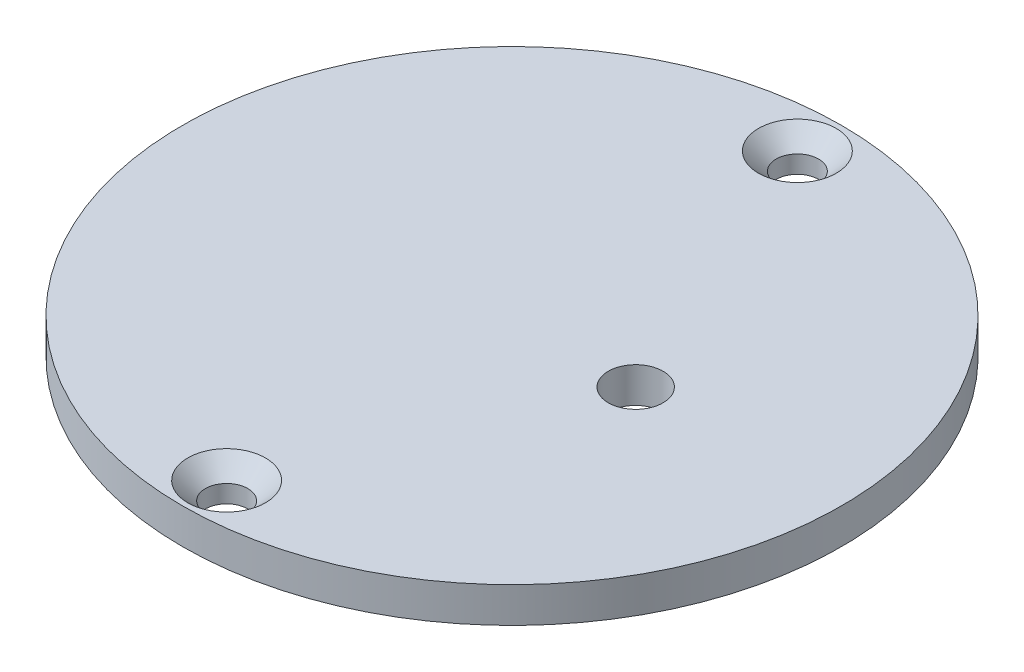
from build123d import *

# Parameters (mm, degrees)
SKETCH_1_R                 = 18.65
EXTRUDE_1_DEPTH            = 2
SKETCH_2_R                 = 1.55
CUT_EXTRUDE_1_DEPTH        = 2
HOLE_WIZARD_M21_AT_2_COUNT = 2
HOLE_WIZARD_M21_AT_2_PITCH = 32.3


with BuildPart() as part:
    # Эскиз1 → Бобышка-Вытянуть1 (new body)
    with BuildSketch(Plane(origin=(0, 0, 0), x_dir=(1, 0, 0), z_dir=(0, 1, 0))):
        Circle(SKETCH_1_R)
    extrude(amount=EXTRUDE_1_DEPTH)

    # Эскиз2 → Вырез-Вытянуть1 (cut)
    with BuildSketch(Plane(origin=(0, 2, 0), x_dir=(1, 0, 0), z_dir=(0, 1, 0))):
        with Locations((7, 0)):
            Circle(SKETCH_2_R)
    extrude(amount=-CUT_EXTRUDE_1_DEPTH, mode=Mode.SUBTRACT)

    # Эскиз4 → Зенковка для  винта с плоской головкой M21 (revolve, cut)
    with BuildSketch(Plane(origin=(0, 2, -16.15), x_dir=(0, 0, 1), z_dir=(1, 0, 0))):
        Polygon((0, 0), (0, 2), (1.2, 2), (1.2, 1), (2.2, 0), align=None)
    hole_wizard_m21 = revolve(axis=Axis((0, 8.35, -16.15), (0, -1, 0)), mode=Mode.SUBTRACT)

    # Зенковка для  винта с плоской головкой M21 at 2: Зенковка для  винта с плоской головкой M21 ×2
    with Locations(*[(0, 0, i * HOLE_WIZARD_M21_AT_2_PITCH) for i in range(1, HOLE_WIZARD_M21_AT_2_COUNT)]):
        add(hole_wizard_m21, mode=Mode.SUBTRACT)


solid = part.part
